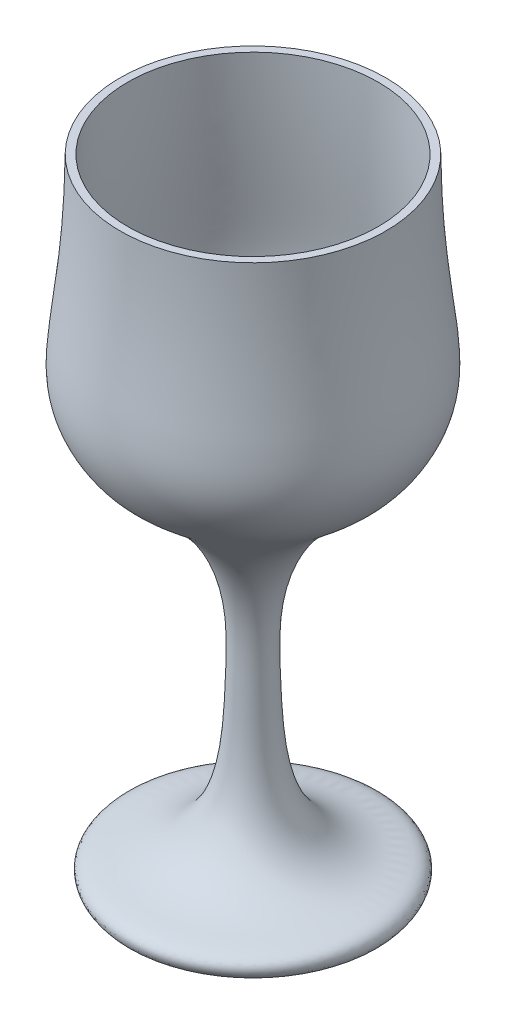
from build123d import *


with BuildPart() as part:
    # Esquisse1 → Révolution1 (revolve)
    with BuildSketch(Plane.XY):
        with BuildLine():
            Line((0, 0), (32.5, 0))
            add(Edge.make_bspline(
                [(32.5, 0), (33.589623702, 1.353069744), (33.137641704, 4.587392776), (7.255838825, 6.637345968), (5.479695222, 31.558246278), (4.068877691, 81.796444825), (27.742644393, 92.091823067), (43.50519477, 116.826103658), (35.436704849, 126.162453137), (35, 165)],
                knots=[0, 0, 0, 0, 0.012064211, 0.033714443, 0.196192557, 0.247333433, 0.493982326, 0.572332094, 1, 1, 1, 1], degree=3))
            Line((35, 165), (33, 165))
            add(Edge.make_bspline(
                [(0, 77.020141492), (6.285777757, 78.185139233), (27.984839266, 95.24083423), (39.775977314, 114.898705323), (33.436704849, 126.162453137), (33, 165)],
                knots=[0.299210169, 0.299210169, 0.299210169, 0.299210169, 0.502253111, 0.572332094, 1, 1, 1, 1], degree=3))
            Line((0, 77.020141492), (0, 0))
        make_face()
    revolve(axis=Axis((0, 0, 0), (0, 1, 0)))


solid = part.part
